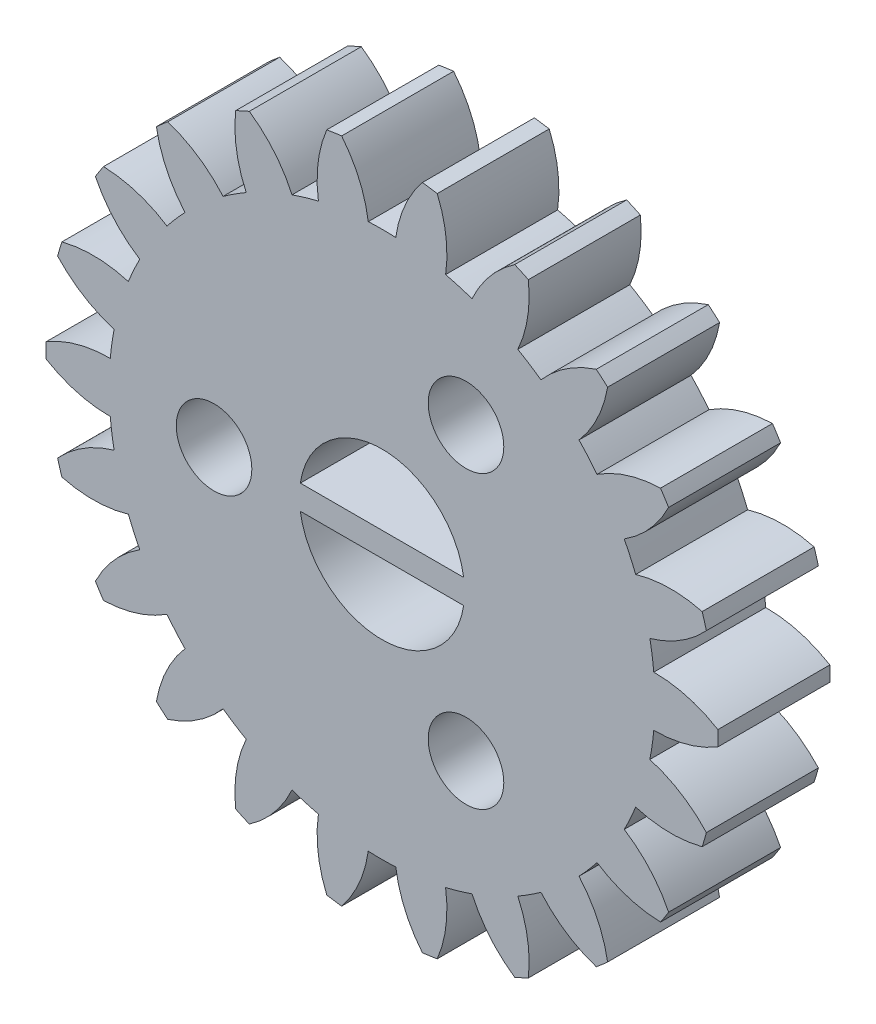
from build123d import *

# Parameters (mm, degrees)
MODEL_R             = 2.5
BOSS_EXTRUDE1_DEPTH = 4
SKETCH2_R           = 2.95
CUT_EXTRUDE1_DEPTH  = 4
SKETCH3_R           = 1.35
CUT_EXTRUDE2_DEPTH  = 4
CIRPATTERN1_COUNT   = 3
BOSS_EXTRUDE2_DEPTH = 4


with BuildPart() as part:
    # Model → Boss-Extrude1 (new body)
    with BuildSketch(Plane.XY):
        with BuildLine():
            ThreePointArc((-11.997000624, 0.268283487), (-12, 0), (-11.997000624, -0.268283487))
            ThreePointArc((-11.997000624, -0.268283487), (-10.895606779, -0.741380557), (-9.707399683, -0.89966238))
            ThreePointArc((-9.707399683, -0.89966238), (-9.649769237, -1.387427358), (-9.56764597, -1.8716708))
            ThreePointArc((-9.56764597, -1.8716708), (-10.663129188, -2.358297721), (-11.586621996, -3.122529539))
            ThreePointArc((-11.586621996, -3.122529539), (-11.513915683, -3.380790682), (-11.43545361, -3.637361781))
            ThreePointArc((-11.43545361, -3.637361781), (-10.245387108, -3.780996591), (-9.060717605, -3.598110265))
            ThreePointArc((-9.060717605, -3.598110265), (-8.868002323, -4.049880962), (-8.652778483, -4.491372344))
            ThreePointArc((-8.652778483, -4.491372344), (-9.566788286, -5.266920743), (-10.237564162, -6.260373793))
            ThreePointArc((-10.237564162, -6.260373793), (-10.095042394, -6.487689809), (-9.947474154, -6.711762656))
            ThreePointArc((-9.947474154, -6.711762656), (-8.765147105, -6.514298768), (-7.679990073, -6.005060656))
            ThreePointArc((-7.679990073, -6.005060656), (-7.3678026, -6.384237295), (-7.036914342, -6.747209612))
            ThreePointArc((-7.036914342, -6.747209612), (-7.695403093, -7.74884917), (-8.059119765, -8.891039794))
            ThreePointArc((-8.059119765, -8.891039794), (-7.858328807, -9.068994892), (-7.653609502, -9.242416436))
            ThreePointArc((-7.653609502, -9.242416436), (-6.574807012, -8.719851201), (-5.67707542, -7.925516745))
            ThreePointArc((-5.67707542, -7.925516745), (-5.270707329, -8.201380692), (-4.850961252, -8.456428084))
            ThreePointArc((-4.850961252, -8.456428084), (-5.200582107, -9.603011921), (-5.227773414, -10.801406627))
            ThreePointArc((-5.227773414, -10.801406627), (-4.984980156, -10.915583944), (-4.739694926, -11.024304604))
            ThreePointArc((-4.739694926, -11.024304604), (-3.851815156, -10.218973149), (-3.214237879, -9.203894603))
            ThreePointArc((-3.214237879, -9.203894603), (-2.746610697, -9.354097), (-2.27201213, -9.480557045))
            ThreePointArc((-2.27201213, -9.480557045), (-2.284440889, -10.679195758), (-1.972903952, -11.836707735))
            ThreePointArc((-1.972903952, -11.836707735), (-1.707778059, -11.877857303), (-1.441798455, -11.913069177))
            ThreePointArc((-1.441798455, -11.913069177), (-0.816772145, -10.890214666), (-0.491001901, -9.736627657))
            ThreePointArc((-0.491001901, -9.736627657), (0, -9.749), (0.491001901, -9.736627657))
            ThreePointArc((0.491001901, -9.736627657), (0.816772145, -10.890214666), (1.441798455, -11.913069177))
            ThreePointArc((1.441798455, -11.913069177), (1.707778059, -11.877857303), (1.972903952, -11.836707735))
            ThreePointArc((1.972903952, -11.836707735), (2.284440889, -10.679195758), (2.27201213, -9.480557045))
            ThreePointArc((2.27201213, -9.480557045), (2.746610697, -9.354097), (3.214237879, -9.203894603))
            ThreePointArc((3.214237879, -9.203894603), (3.851815156, -10.218973149), (4.739694926, -11.024304604))
            ThreePointArc((4.739694926, -11.024304604), (4.984980156, -10.915583944), (5.227773414, -10.801406627))
            ThreePointArc((5.227773414, -10.801406627), (5.200582107, -9.603011921), (4.850961252, -8.456428084))
            ThreePointArc((4.850961252, -8.456428084), (5.270707329, -8.201380692), (5.67707542, -7.925516745))
            ThreePointArc((5.67707542, -7.925516745), (6.574807012, -8.719851201), (7.653609502, -9.242416436))
            ThreePointArc((7.653609502, -9.242416436), (7.858328807, -9.068994892), (8.059119765, -8.891039794))
            ThreePointArc((8.059119765, -8.891039794), (7.695403093, -7.74884917), (7.036914342, -6.747209612))
            ThreePointArc((7.036914342, -6.747209612), (7.3678026, -6.384237295), (7.679990073, -6.005060656))
            ThreePointArc((7.679990073, -6.005060656), (8.765147105, -6.514298768), (9.947474154, -6.711762656))
            ThreePointArc((9.947474154, -6.711762656), (10.095042394, -6.487689809), (10.237564162, -6.260373793))
            ThreePointArc((10.237564162, -6.260373793), (9.566788286, -5.266920743), (8.652778482, -4.491372344))
            ThreePointArc((8.652778482, -4.491372344), (8.868002323, -4.049880962), (9.060717605, -3.598110265))
            ThreePointArc((9.060717605, -3.598110265), (10.245387108, -3.780996591), (11.43545361, -3.637361781))
            ThreePointArc((11.43545361, -3.637361781), (11.513915683, -3.380790682), (11.586621996, -3.122529539))
            ThreePointArc((11.586621996, -3.122529539), (10.663129188, -2.358297721), (9.56764597, -1.8716708))
            ThreePointArc((9.56764597, -1.8716708), (9.649769237, -1.387427358), (9.707399683, -0.89966238))
            ThreePointArc((9.707399683, -0.89966238), (10.895606779, -0.741380557), (11.997000624, -0.268283487))
            ThreePointArc((11.997000624, -0.268283487), (12, 0), (11.997000624, 0.268283487))
            ThreePointArc((11.997000624, 0.268283487), (10.895606779, 0.741380557), (9.707399683, 0.89966238))
            ThreePointArc((9.707399683, 0.89966238), (9.649769237, 1.387427358), (9.56764597, 1.8716708))
            ThreePointArc((9.56764597, 1.8716708), (10.663129188, 2.358297721), (11.586621996, 3.122529539))
            ThreePointArc((11.586621996, 3.122529539), (11.513915683, 3.380790682), (11.43545361, 3.637361781))
            ThreePointArc((11.43545361, 3.637361781), (10.245387108, 3.780996591), (9.060717605, 3.598110265))
            ThreePointArc((9.060717605, 3.598110265), (8.868002323, 4.049880962), (8.652778483, 4.491372344))
            ThreePointArc((8.652778483, 4.491372344), (9.566788286, 5.266920743), (10.237564162, 6.260373793))
            ThreePointArc((10.237564162, 6.260373793), (10.095042394, 6.487689809), (9.947474154, 6.711762656))
            ThreePointArc((9.947474154, 6.711762656), (8.765147105, 6.514298768), (7.679990073, 6.005060656))
            ThreePointArc((7.679990073, 6.005060656), (7.3678026, 6.384237295), (7.036914342, 6.747209612))
            ThreePointArc((7.036914342, 6.747209612), (7.695403093, 7.74884917), (8.059119765, 8.891039794))
            ThreePointArc((8.059119765, 8.891039794), (7.858328807, 9.068994892), (7.653609502, 9.242416436))
            ThreePointArc((7.653609502, 9.242416436), (6.574807012, 8.719851201), (5.67707542, 7.925516745))
            ThreePointArc((5.67707542, 7.925516745), (5.270707329, 8.201380692), (4.850961252, 8.456428084))
            ThreePointArc((4.850961252, 8.456428084), (5.200582107, 9.603011921), (5.227773414, 10.801406627))
            ThreePointArc((5.227773414, 10.801406627), (4.984980156, 10.915583944), (4.739694926, 11.024304604))
            ThreePointArc((4.739694926, 11.024304604), (3.851815156, 10.218973149), (3.214237879, 9.203894603))
            ThreePointArc((3.214237879, 9.203894603), (2.746610697, 9.354097), (2.27201213, 9.480557045))
            ThreePointArc((2.27201213, 9.480557045), (2.284440889, 10.679195758), (1.972903952, 11.836707735))
            ThreePointArc((1.972903952, 11.836707735), (1.707778059, 11.877857303), (1.441798455, 11.913069177))
            ThreePointArc((1.441798455, 11.913069177), (0.816772145, 10.890214666), (0.491001901, 9.736627657))
            ThreePointArc((0.491001901, 9.736627657), (0, 9.749), (-0.491001901, 9.736627657))
            ThreePointArc((-0.491001901, 9.736627657), (-0.816772145, 10.890214666), (-1.441798455, 11.913069177))
            ThreePointArc((-1.441798455, 11.913069177), (-1.707778059, 11.877857303), (-1.972903952, 11.836707735))
            ThreePointArc((-1.972903952, 11.836707735), (-2.284440889, 10.679195758), (-2.27201213, 9.480557045))
            ThreePointArc((-2.27201213, 9.480557045), (-2.746610697, 9.354097), (-3.214237879, 9.203894603))
            ThreePointArc((-3.214237879, 9.203894603), (-3.851815156, 10.218973149), (-4.739694926, 11.024304604))
            ThreePointArc((-4.739694926, 11.024304604), (-4.984980156, 10.915583944), (-5.227773414, 10.801406627))
            ThreePointArc((-5.227773414, 10.801406627), (-5.200582107, 9.603011921), (-4.850961252, 8.456428084))
            ThreePointArc((-4.850961252, 8.456428084), (-5.270707329, 8.201380692), (-5.67707542, 7.925516745))
            ThreePointArc((-5.67707542, 7.925516745), (-6.574807012, 8.719851201), (-7.653609502, 9.242416436))
            ThreePointArc((-7.653609502, 9.242416436), (-7.858328807, 9.068994892), (-8.059119765, 8.891039794))
            ThreePointArc((-8.059119765, 8.891039794), (-7.695403093, 7.74884917), (-7.036914342, 6.747209612))
            ThreePointArc((-7.036914342, 6.747209612), (-7.3678026, 6.384237295), (-7.679990073, 6.005060656))
            ThreePointArc((-7.679990073, 6.005060656), (-8.765147105, 6.514298768), (-9.947474154, 6.711762656))
            ThreePointArc((-9.947474154, 6.711762656), (-10.095042394, 6.487689809), (-10.237564162, 6.260373793))
            ThreePointArc((-10.237564162, 6.260373793), (-9.566788286, 5.266920743), (-8.652778482, 4.491372344))
            ThreePointArc((-8.652778482, 4.491372344), (-8.868002323, 4.049880962), (-9.060717605, 3.598110265))
            ThreePointArc((-9.060717605, 3.598110265), (-10.245387108, 3.780996591), (-11.43545361, 3.637361781))
            ThreePointArc((-11.43545361, 3.637361781), (-11.513915683, 3.380790682), (-11.586621996, 3.122529539))
            ThreePointArc((-11.586621996, 3.122529539), (-10.663129188, 2.358297721), (-9.56764597, 1.8716708))
            ThreePointArc((-9.56764597, 1.8716708), (-9.649769237, 1.387427358), (-9.707399683, 0.89966238))
            ThreePointArc((-9.707399683, 0.89966238), (-10.895606779, 0.741380557), (-11.997000624, 0.268283487))
        make_face()
        Circle(MODEL_R, mode=Mode.SUBTRACT)
    extrude(amount=BOSS_EXTRUDE1_DEPTH)

    # Sketch2 → Cut-Extrude1 (cut)
    with BuildSketch(Plane.XY.offset(4)):
        Circle(SKETCH2_R)
    extrude(amount=-CUT_EXTRUDE1_DEPTH, mode=Mode.SUBTRACT)

    # Sketch3 → Cut-Extrude2 (cut)
    with BuildSketch(Plane.XY.offset(4)):
        with Locations((-6, 0)):
            Circle(SKETCH3_R)
    cut_extrude2 = extrude(amount=-CUT_EXTRUDE2_DEPTH, mode=Mode.SUBTRACT)

    # CirPattern1: Cut-Extrude2 ×3 about axis
    cirpattern1_axis = Axis((0, 0, 0), (0, 0, 1))
    for i in range(1, CIRPATTERN1_COUNT):
        add(cut_extrude2.rotate(cirpattern1_axis, i * 360 / CIRPATTERN1_COUNT), mode=Mode.SUBTRACT)

    # Sketch5 → Boss-Extrude2 (add)
    with BuildSketch(Plane.XY):
        with BuildLine():
            ThreePointArc((-2.95, 0), (-2.941926879, -0.218096855), (-2.917751703, -0.435))
            Line((-2.917751703, -0.435), (2.917751703, -0.435))
            ThreePointArc((2.917751703, -0.435), (2.941926879, -0.218096855), (2.95, 0))
            ThreePointArc((2.95, 0), (2.941926879, 0.218096855), (2.917751703, 0.435))
            Line((2.917751703, 0.435), (-2.917751703, 0.435))
            ThreePointArc((-2.917751703, 0.435), (-2.941926879, 0.218096855), (-2.95, 0))
        make_face()
    extrude(amount=BOSS_EXTRUDE2_DEPTH)


solid = part.part
